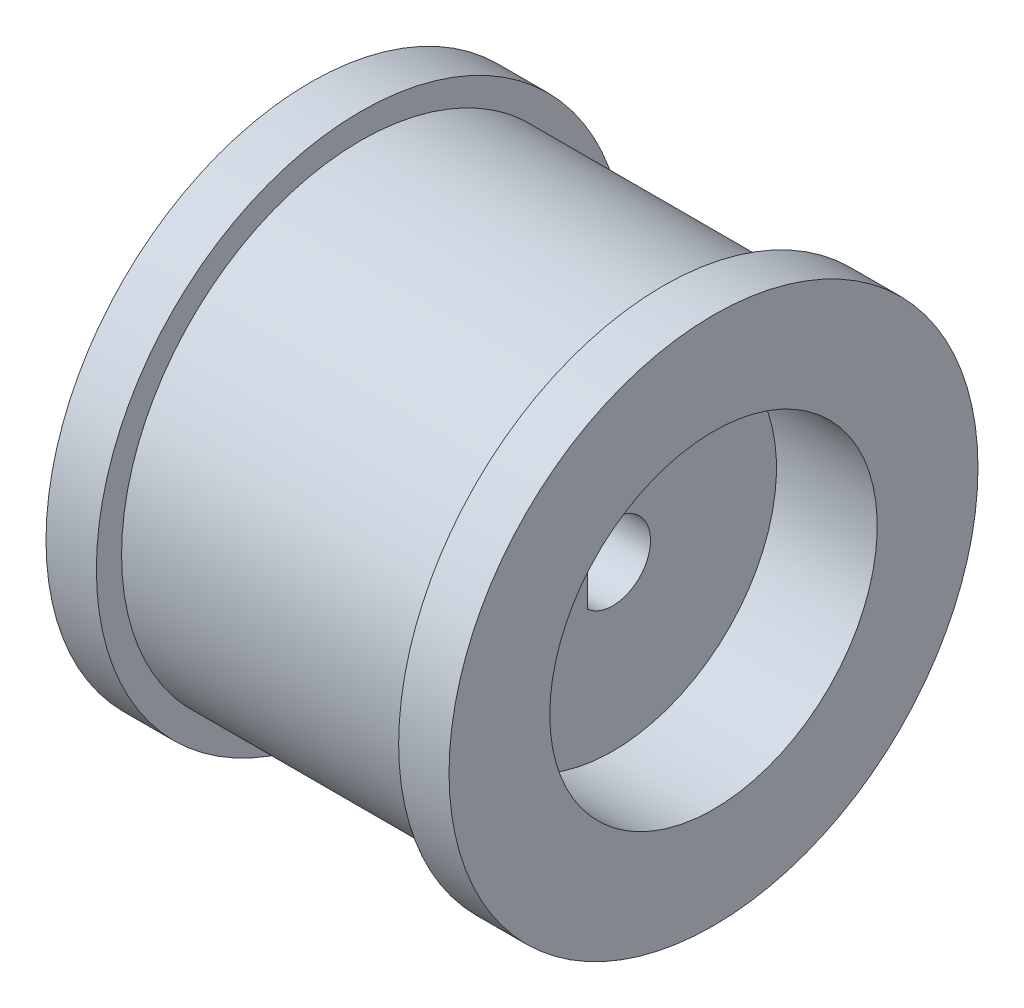
from build123d import *

# Parameters (mm, degrees)
CUT_EXTRUDE1_DEPTH = 10


with BuildPart() as part:
    # Sketch1 → Revolve1 (revolve)
    with BuildSketch(Plane.XY):
        Polygon((6, 9.5), (-6, 9.5), (-6, 10.5), (-8, 10.5), (-8, 6.5), (-4, 6.5), (-4, 0), (4, 0), (4, 6.5), (8, 6.5), (8, 10.5), (6, 10.5), align=None)
    revolve(axis=Axis((-167.001765705, 0, 0), (1, 0, 0)))

    # Sketch2 → Cut-Extrude1 (cut)
    with BuildSketch(Plane(origin=(4, 0, 0), x_dir=(0, 0, -1), z_dir=(1, 0, 0))):
        with BuildLine():
            Line((-1, 1.118033989), (-1, -1.118033989))
            ThreePointArc((-1, -1.118033989), (1.5, 0), (-1, 1.118033989))
        make_face()
    extrude(amount=-CUT_EXTRUDE1_DEPTH, mode=Mode.SUBTRACT)


solid = part.part
